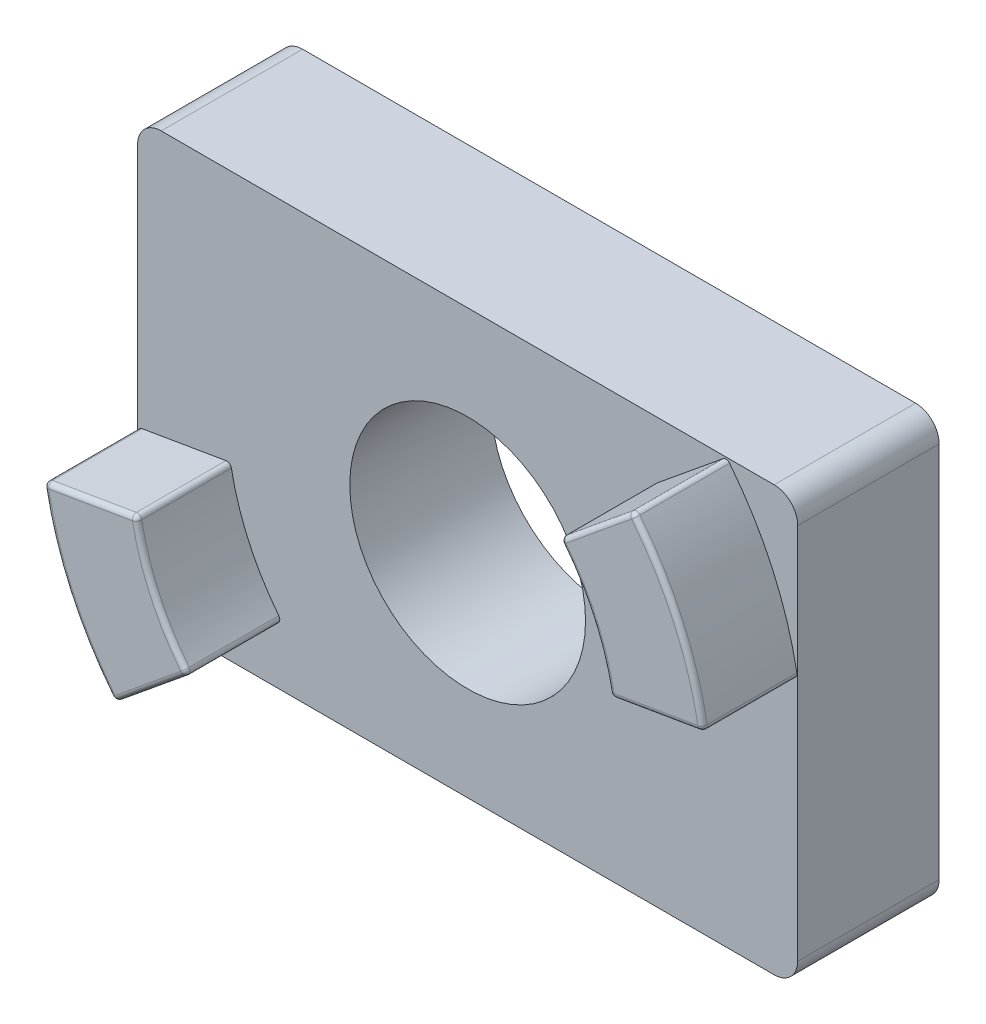
from build123d import *

# Parameters (mm, degrees)
SKETCH1_W           = 14
SKETCH1_H           = 9
SKETCH1_R           = 2.5
BOSS_EXTRUDE1_DEPTH = 3
FILLET1_R           = 0.5
BOSS_EXTRUDE2_DEPTH = 2
FILLET2_R           = 0.1


with BuildPart() as part:
    # Sketch1 → Boss-Extrude1 (new body)
    with BuildSketch(Plane.XY):
        Rectangle(SKETCH1_W, SKETCH1_H)
        Circle(SKETCH1_R, mode=Mode.SUBTRACT)
    extrude(amount=BOSS_EXTRUDE1_DEPTH)

    # Fillet1
    fillet1_edges = [part.edges().sort_by_distance(p)[0] for p in [
        (-7, 4.5, 1.5),
        (7, 4.5, 1.5),
        (7, -4.5, 1.5),
        (-7, -4.5, 1.5),
    ]]
    fillet(fillet1_edges, radius=FILLET1_R)

    # Sketch2 → Boss-Extrude2 (add)
    with BuildSketch(Plane.XY.offset(3)):
        with BuildLine():
            Line((-5.028169014, -0.852945699), (-7, -1.187434209))
            ThreePointArc((-7, -1.187434209), (-6.461781127, -2.942003512), (-5.491812087, -4.5))
            Line((-5.491812087, -4.5), (-3.944822767, -3.232394366))
            ThreePointArc((-3.944822767, -3.232394366), (-4.641561091, -2.113270128), (-5.028169014, -0.852945699))
        make_face()
        with BuildLine():
            Line((5.491812087, 4.5), (3.944822767, 3.232394366))
            ThreePointArc((3.944822767, 3.232394366), (4.641561091, 2.113270128), (5.028169014, 0.852945699))
            Line((5.028169014, 0.852945699), (7, 1.187434209))
            ThreePointArc((7, 1.187434209), (6.461781127, 2.942003512), (5.491812087, 4.5))
        make_face()
    extrude(amount=BOSS_EXTRUDE2_DEPTH)

    # Fillet2
    fillet2_edges = [part.edges().sort_by_distance(p)[0] for p in [
        (-5.028169014, -0.852945699, 4),
        (-7, -1.187434209, 4),
        (-5.491812087, -4.5, 4),
        (-4.641561091, -2.113270128, 5),
        (-3.944822767, -3.232394366, 4),
        (-6.014084507, -1.020189954, 5),
        (-6.461781127, -2.942003512, 5),
        (-4.718317427, -3.866197183, 5),
        (5.491812087, 4.5, 4),
        (3.944822767, 3.232394366, 4),
        (6.014084507, 1.020189954, 5),
        (5.028169014, 0.852945699, 4),
        (6.461781127, 2.942003512, 5),
        (7, 1.187434209, 4),
        (4.718317427, 3.866197183, 5),
        (4.641561091, 2.113270128, 5),
    ]]
    fillet(fillet2_edges, radius=FILLET2_R)


solid = part.part
